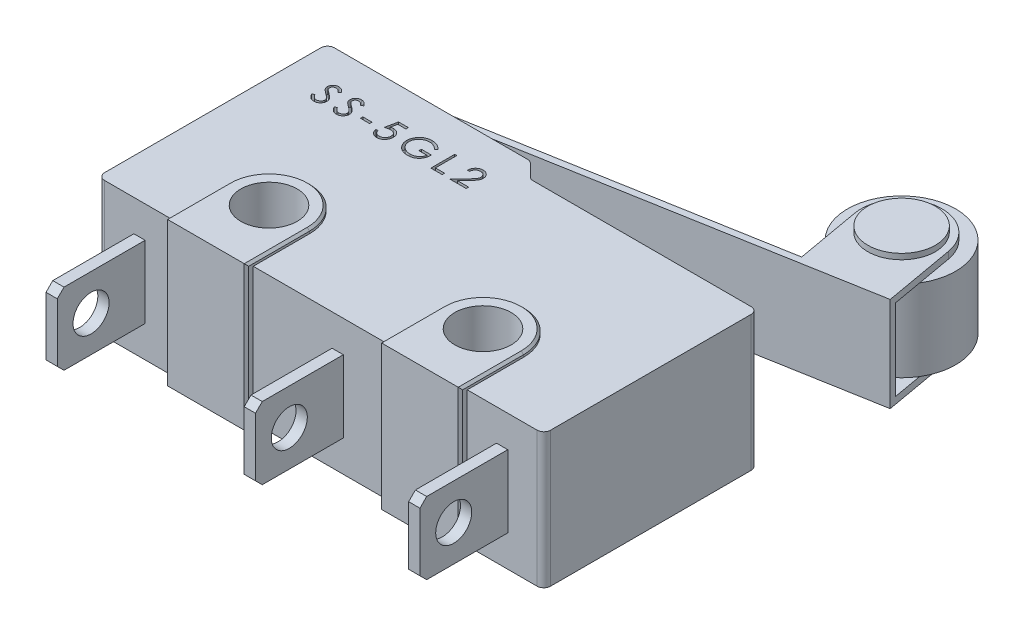
from build123d import *

# Parameters (mm, degrees)
BASE_EXTRUDE_DEPTH       = 6
SKETCH2_R                = 1.25
CUT_EXTRUDE1_DEPTH       = 24.066859344
SKETCH3_R                = 1.25
BOSS_EXTRUDE1_DEPTH      = 0.2
SKETCH4_R                = 1.25
BOSS_EXTRUDE2_DEPTH      = 0.2
CHAMFER1_SIZE            = 0.1
SKETCH5_W                = 2
SKETCH5_H                = 3.2
BOSS_EXTRUDE3_DEPTH      = 1.2
FILLET1_R                = 0.7
SKETCH6_W                = 0.5
SKETCH6_H                = 3.2
BOSS_EXTRUDE4_DEPTH      = 3.9
CHAMFER2_SIZE            = 0.3
SKETCH7_R                = 0.8
CUT_EXTRUDE2_DEPTH       = 23.352628481
BOSS_EXTRUDE5_DEPTH      = 0.3
CHAMFER3_SIZE            = 0.1
BOSS_EXTRUDE6_DEPTH      = 2.1
BOSS_EXTRUDE6_DEPTH_BACK = 2.1
SKETCH12_W               = 0.407051282
SKETCH12_H               = 0.108547009
CUT_EXTRUDE3_DEPTH       = 0.3
SKETCH13_R               = 1.5
EXTRUDE1_DEPTH           = 0.25
SKETCH14_R               = 0.9
EXTRUDE2_DEPTH           = 0.25
SKETCH15_W               = 3.6
SKETCH15_H               = 3.6
CUT_EXTRUDE4_DEPTH       = 28.708764663
SKETCH16_R               = 2.4
EXTRUDE3_DEPTH           = 3.6


with BuildPart() as part:
    # Sketch1 → Base-Extrude (new body)
    with BuildSketch(Plane(origin=(0, 0, 0), x_dir=(1, 0, 0), z_dir=(0, 1, 0))):
        with BuildLine():
            Line((19.5, 9.5), (9.824264069, 9.5))
            ThreePointArc((9.824264069, 9.5), (9.709459039, 9.52283614), (9.612132034, 9.587867966))
            Line((9.612132034, 9.587867966), (9.087867966, 10.112132034))
            ThreePointArc((9.087867966, 10.112132034), (8.990540961, 10.17716386), (8.875735931, 10.2))
            Line((8.875735931, 10.2), (0.3, 10.2))
            ThreePointArc((0.3, 10.2), (0.087867966, 10.112132034), (0, 9.9))
            Line((0, 9.9), (0, 0.3))
            ThreePointArc((0, 0.3), (0.087867966, 0.087867966), (0.3, 0))
            Line((0.3, 0), (19.5, 0))
            ThreePointArc((19.5, 0), (19.712132034, 0.087867966), (19.8, 0.3))
            Line((19.8, 0.3), (19.8, 9.2))
            ThreePointArc((19.8, 9.2), (19.712132034, 9.412132034), (19.5, 9.5))
        make_face()
    extrude(amount=BASE_EXTRUDE_DEPTH)

    # Sketch2 → Cut-Extrude1 (cut, through all)
    with BuildSketch(Plane(origin=(0, 6, 0), x_dir=(-1, 0, 0), z_dir=(0, 1, 0))):
        with Locations(Location((-5.1, -2.5, 0), (0, 0, 90))):
            Circle(SKETCH2_R)
        with Locations(Location((-14.6, -2.5, 0), (0, 0, 90))):
            Circle(SKETCH2_R)
    extrude(amount=-CUT_EXTRUDE1_DEPTH, mode=Mode.SUBTRACT)

    # Sketch3 → Boss-Extrude1 (add)
    with BuildSketch(Plane(origin=(0, 6, 0), x_dir=(-1, 0, 0), z_dir=(0, 1, 0))):
        with BuildLine():
            Line((-3.3, 0), (-6.9, 0))
            Line((-6.9, 0), (-6.9, -2.5))
            ThreePointArc((-6.9, -2.5), (-5.1, -4.3), (-3.3, -2.5))
            Line((-3.3, -2.5), (-3.3, 0))
        make_face()
        with Locations(Location((-5.1, -2.5, 0), (0, 0, 90))):
            Circle(SKETCH3_R, mode=Mode.SUBTRACT)
        with BuildLine():
            Line((-12.8, -2.5), (-12.8, 0))
            Line((-12.8, 0), (-16.4, 0))
            Line((-16.4, 0), (-16.4, -2.5))
            ThreePointArc((-16.4, -2.5), (-14.6, -4.3), (-12.8, -2.5))
        make_face()
        with Locations(Location((-14.6, -2.5, 0), (0, 0, 90))):
            Circle(SKETCH3_R, mode=Mode.SUBTRACT)
    extrude(amount=BOSS_EXTRUDE1_DEPTH)

    # Sketch4 → Boss-Extrude2 (add)
    with BuildSketch(Plane.XZ):
        with BuildLine():
            Line((16.4, 0), (12.8, 0))
            Line((12.8, 0), (12.8, -2.5))
            ThreePointArc((12.8, -2.5), (14.6, -4.3), (16.4, -2.5))
            Line((16.4, -2.5), (16.4, 0))
        make_face()
        with Locations(Location((14.6, -2.5, 0), (0, 0, 90))):
            Circle(SKETCH4_R, mode=Mode.SUBTRACT)
        with BuildLine():
            Line((3.3, 0), (3.3, -2.5))
            ThreePointArc((3.3, -2.5), (5.1, -4.3), (6.9, -2.5))
            Line((6.9, -2.5), (6.9, 0))
            Line((6.9, 0), (3.3, 0))
        make_face()
        with Locations(Location((5.1, -2.5, 0), (0, 0, 90))):
            Circle(SKETCH4_R, mode=Mode.SUBTRACT)
    extrude(amount=BOSS_EXTRUDE2_DEPTH)

    # Chamfer1
    chamfer1_edges = [part.edges().sort_by_distance(p)[0] for p in [
        (3.3, 6.2, -1.25),
        (6.9, 6.2, -1.25),
        (5.1, 6.2, -4.3),
        (16.4, 6.2, -1.25),
        (14.6, 6.2, -4.3),
        (12.8, 6.2, -1.25),
        (12.8, -0.2, -1.25),
        (14.6, -0.2, -4.3),
        (16.4, -0.2, -1.25),
        (5.1, -0.2, -4.3),
        (6.9, -0.2, -1.25),
        (3.3, -0.2, -1.25),
    ]]
    chamfer(chamfer1_edges, length=CHAMFER1_SIZE)

    # Sketch5 → Boss-Extrude3 (add)
    with BuildSketch(Plane(origin=(0, 0, -10.2), x_dir=(-1, 0, 0), z_dir=(0, 0, -1))):
        with Locations((-7.1, 3)):
            Rectangle(SKETCH5_W, SKETCH5_H)
    extrude(amount=BOSS_EXTRUDE3_DEPTH)

    # Fillet1
    fillet1_edges = [part.edges().sort_by_distance(p)[0] for p in [
        (8.1, 3, -11.4),
        (6.1, 3, -11.4),
    ]]
    fillet(fillet1_edges, radius=FILLET1_R)

    # Sketch6 → Boss-Extrude4 (add)
    with BuildSketch(Plane.XY):
        with Locations((1.85, 3)):
            Rectangle(SKETCH6_W, SKETCH6_H)
        with Locations((10.65, 3)):
            Rectangle(SKETCH6_W, SKETCH6_H)
        with Locations((17.95, 3)):
            Rectangle(SKETCH6_W, SKETCH6_H)
    extrude(amount=BOSS_EXTRUDE4_DEPTH)

    # Chamfer2
    chamfer2_edges = [part.edges().sort_by_distance(p)[0] for p in [
        (1.85, 1.4, 3.9),
        (1.85, 4.6, 3.9),
        (10.65, 1.4, 3.9),
        (10.65, 4.6, 3.9),
        (17.95, 1.4, 3.9),
        (17.95, 4.6, 3.9),
    ]]
    chamfer(chamfer2_edges, length=CHAMFER2_SIZE)

    # Sketch7 → Cut-Extrude2 (cut, through all)
    with BuildSketch(Plane.ZY.offset(-1.6)):
        with Locations((2.4, 3)):
            Circle(SKETCH7_R)
    extrude(amount=-CUT_EXTRUDE2_DEPTH, mode=Mode.SUBTRACT)

    # Sketch8 → Boss-Extrude5 (add)
    with BuildSketch(Plane.XY):
        Polygon((16.4, -0.1), (16.4, 6.1), (16.3, 6.2), (12.9, 6.2), (12.8, 6.1), (12.8, -0.1), (12.9, -0.2), (16.3, -0.2), align=None)
        Polygon((6.9, -0.1), (6.9, 6.1), (6.8, 6.2), (3.4, 6.2), (3.3, 6.1), (3.3, -0.1), (3.4, -0.2), (6.8, -0.2), align=None)
    extrude(amount=BOSS_EXTRUDE5_DEPTH)

    # Chamfer3
    chamfer3_edges = [part.edges().sort_by_distance(p)[0] for p in [
        (12.8, 3, 0.3),
        (16.4, 3, 0.3),
        (3.3, 3, 0.3),
        (6.9, 3, 0.3),
    ]]
    chamfer(chamfer3_edges, length=CHAMFER3_SIZE)

    # Sketch11 → Boss-Extrude6 (add, two sides)
    with BuildSketch(Plane(origin=(0, 3, 0), x_dir=(-1, 0, 0), z_dir=(0, 1, 0))) as boss_extrude6_sk:
        with BuildLine():
            Line((-17.815964753, -13.430390492), (-2.947649136, -10.795396999))
            ThreePointArc((-2.947649136, -10.795396999), (-2.770103002, -10.692736531), (-2.7, -10.5))
            Line((-2.7, -10.5), (-2.7, -10.2))
            Line((-2.7, -10.2), (-3, -10.2))
            Line((-3, -10.2), (-3, -10.5))
            Line((-3, -10.5), (-21.413079605, -13.763203862))
            Line((-21.413079605, -13.763203862), (-20.854670388, -16.914105185))
            ThreePointArc((-20.854670388, -16.914105185), (-18.76818321, -18.372381994), (-17.3099064, -16.285894815))
            Line((-17.3099064, -16.285894815), (-17.815964753, -13.430390492))
        make_face()
    extrude(amount=BOSS_EXTRUDE6_DEPTH)
    extrude(boss_extrude6_sk.sketch, amount=-BOSS_EXTRUDE6_DEPTH_BACK)

    # Sketch12 → Cut-Extrude3 (cut)
    with BuildSketch(Plane(origin=(-12.497117176, 6, -3.291404599), x_dir=(1, 0, 0), z_dir=(0, 1, 0))):
        with BuildLine():
            Line((14.069489931, 4.629493769), (14.158956411, 4.683131256))
            add(Edge.make_bspline(
                [(14.158956411, 4.683131256), (14.167277401, 4.669202263), (14.183220099, 4.642514851), (14.209814914, 4.606453491), (14.237371771, 4.575803506), (14.266094736, 4.550743198), (14.295808487, 4.531013178), (14.326706999, 4.517042503), (14.358686146, 4.508329101), (14.380449659, 4.507270741), (14.391314851, 4.506742367)],
                knots=[0, 0, 0, 0, 1.272034388, 2.437168799, 3.508375237, 4.49857839, 5.41946034, 6.295179144, 7.148887113, 8, 8, 8, 8], degree=3))
            add(Edge.make_bspline(
                [(14.391314851, 4.506742367), (14.400593973, 4.507000804), (14.418989854, 4.507513155), (14.446071771, 4.512436159), (14.472373411, 4.519999351), (14.497352689, 4.530830918), (14.520664935, 4.543935651), (14.541107912, 4.559764138), (14.558780903, 4.577485538), (14.573237469, 4.597256007), (14.584328813, 4.618518574), (14.592853557, 4.640343207), (14.597584329, 4.66307275), (14.598296967, 4.67837639), (14.598656598, 4.686099338)],
                knots=[0, 0, 0, 0, 1.095163259, 2.171163733, 3.241058638, 4.321873601, 5.38011039, 6.391990106, 7.366004449, 8.327778327, 9.272591725, 10.192022065, 11.087607919, 12, 12, 12, 12], degree=3))
            add(Edge.make_bspline(
                [(14.598656598, 4.686099338), (14.598210794, 4.694910976), (14.597304541, 4.712823748), (14.589644784, 4.739251738), (14.577595131, 4.765405444), (14.566478807, 4.781583208), (14.560707546, 4.789982217)],
                knots=[0, 0, 0, 0, 0.938893495, 1.908633276, 2.914225137, 4, 4, 4, 4], degree=3))
            add(Edge.make_bspline(
                [(14.560707546, 4.789982217), (14.555969051, 4.796043995), (14.546021173, 4.808769939), (14.528919258, 4.827712665), (14.508851409, 4.847252044), (14.486504382, 4.868134187), (14.461064138, 4.889387878), (14.433327485, 4.912026619), (14.402586271, 4.935189477), (14.381026661, 4.950723562), (14.369902257, 4.958738895)],
                knots=[0, 0, 0, 0, 0.722233717, 1.516239348, 2.393582979, 3.351407094, 4.387010283, 5.505090956, 6.712668013, 8, 8, 8, 8], degree=3))
            add(Edge.make_bspline(
                [(14.369902257, 4.958738895), (14.358767382, 4.96666992), (14.337478349, 4.981833436), (14.307706349, 5.004337922), (14.281083381, 5.024913092), (14.257727773, 5.043752639), (14.2376498, 5.060859117), (14.220691245, 5.076068256), (14.20728411, 5.08979138), (14.199828732, 5.098693881), (14.196481451, 5.102690885)],
                knots=[0, 0, 0, 0, 1.452282411, 2.77665338, 3.964542531, 5.026858415, 5.96415736, 6.766646006, 7.446254459, 8, 8, 8, 8], degree=3))
            add(Edge.make_bspline(
                [(14.196481451, 5.102690885), (14.191802848, 5.108920246), (14.182601747, 5.12117112), (14.170456312, 5.140319351), (14.16013328, 5.159920672), (14.15204086, 5.180027755), (14.145226337, 5.200358317), (14.140642867, 5.221177622), (14.13777285, 5.242392252), (14.137478939, 5.256668715), (14.137331811, 5.26381535)],
                knots=[0, 0, 0, 0, 1.068054152, 2.10047183, 3.106115577, 4.101338837, 5.06977816, 6.043150881, 7.020423561, 8, 8, 8, 8], degree=3))
            add(Edge.make_bspline(
                [(14.137331811, 5.26381535), (14.137726482, 5.275012449), (14.138507387, 5.297167316), (14.145111543, 5.3295314), (14.155535489, 5.360430626), (14.170138944, 5.389559084), (14.188964381, 5.416158321), (14.210749712, 5.440534304), (14.236697471, 5.461026233), (14.26516743, 5.478930831), (14.296329714, 5.492944956), (14.328984107, 5.503516491), (14.363182507, 5.509506433), (14.386345836, 5.510366031), (14.398099039, 5.510802196)],
                knots=[0, 0, 0, 0, 1.005424448, 1.989358655, 2.955360095, 3.929531133, 4.905563448, 5.876582895, 6.856512386, 7.866279853, 8.892233794, 9.918561126, 10.94386622, 12, 12, 12, 12], degree=3))
            add(Edge.make_bspline(
                [(14.398099039, 5.510802196), (14.410570469, 5.510372043), (14.435372164, 5.509516607), (14.471854188, 5.502078782), (14.506978976, 5.489771675), (14.53523444, 5.475805104), (14.557348394, 5.461855843), (14.574213006, 5.449149848), (14.591302807, 5.434522137), (14.608755647, 5.417933746), (14.626275799, 5.399232466), (14.644123366, 5.378546377), (14.662340086, 5.356001895), (14.67405912, 5.339907819), (14.680066854, 5.331657231)],
                knots=[0, 0, 0, 0, 1.286793592, 2.559021753, 3.825965368, 5.121522368, 5.803751409, 6.523245864, 7.299691795, 8.125521123, 9.008227632, 9.944561021, 10.946284179, 12, 12, 12, 12], degree=3))
            Line((14.680066854, 5.331657231), (14.594204474, 5.266571427))
            add(Edge.make_bspline(
                [(14.594204474, 5.266571427), (14.589019871, 5.273250626), (14.579035537, 5.286113202), (14.563877335, 5.304126433), (14.549590244, 5.32058094), (14.53551429, 5.334873015), (14.522392882, 5.347785326), (14.509657491, 5.3588403), (14.497491389, 5.368146254), (14.482155561, 5.378077521), (14.462888537, 5.387921988), (14.438702737, 5.396252304), (14.413427839, 5.40125824), (14.396213403, 5.401920117), (14.387498745, 5.402255187)],
                knots=[0, 0, 0, 0, 1.181633172, 2.275549214, 3.290209073, 4.226197932, 5.078386478, 5.862611352, 6.581680152, 7.217281963, 8.414376989, 9.595101626, 10.782541182, 12, 12, 12, 12], degree=3))
            add(Edge.make_bspline(
                [(14.387498745, 5.402255187), (14.376565701, 5.401888792), (14.355482357, 5.401182234), (14.325549595, 5.393465477), (14.298609289, 5.381315248), (14.275461251, 5.364286671), (14.256188403, 5.344111514), (14.242246991, 5.32089505), (14.23385587, 5.295258467), (14.232831923, 5.277375156), (14.232310444, 5.268267474)],
                knots=[0, 0, 0, 0, 1.14458467, 2.207223713, 3.21896685, 4.227309161, 5.202851033, 6.127160689, 7.046193047, 8, 8, 8, 8], degree=3))
            add(Edge.make_bspline(
                [(14.232310444, 5.268267474), (14.232429318, 5.262597384), (14.23266726, 5.251247932), (14.23598583, 5.234480478), (14.240249199, 5.217755383), (14.247005185, 5.20114784), (14.256332217, 5.184367403), (14.268580211, 5.167125116), (14.284005665, 5.149269004), (14.295821809, 5.137655345), (14.302060377, 5.131523684)],
                knots=[0, 0, 0, 0, 0.858281714, 1.717966888, 2.583508476, 3.4729293, 4.427298488, 5.488583878, 6.674047936, 8, 8, 8, 8], degree=3))
            add(Edge.make_bspline(
                [(14.302060377, 5.131523684), (14.30437703, 5.129456297), (14.309880868, 5.12454466), (14.319942874, 5.116503661), (14.333230339, 5.106584728), (14.34939629, 5.094311896), (14.368738802, 5.080075359), (14.391260001, 5.064057148), (14.416708846, 5.045737259), (14.434767615, 5.032929145), (14.44431632, 5.026156763)],
                knots=[0, 0, 0, 0, 0.420754252, 0.999615792, 1.744751191, 2.668019286, 3.750313428, 4.999500688, 6.413464383, 8, 8, 8, 8], degree=3))
            add(Edge.make_bspline(
                [(14.44431632, 5.026156763), (14.455802537, 5.017798543), (14.478044003, 5.001614007), (14.509690462, 4.977297837), (14.538384542, 4.95351625), (14.564226987, 4.930421116), (14.5874731, 4.908187621), (14.607864982, 4.886548279), (14.625610414, 4.865658117), (14.644714606, 4.838875458), (14.664235661, 4.80598213), (14.681000117, 4.765681329), (14.691570855, 4.72522387), (14.692953194, 4.698031708), (14.69363523, 4.684615297)],
                knots=[0, 0, 0, 0, 1.163667725, 2.253281268, 3.268753668, 4.215851969, 5.092017293, 5.902905408, 6.650798638, 7.335211899, 8.59617414, 9.77448103, 10.901945474, 12, 12, 12, 12], degree=3))
            add(Edge.make_bspline(
                [(14.69363523, 4.684615297), (14.693436524, 4.675127077), (14.693042971, 4.656334892), (14.688519075, 4.628741095), (14.681890986, 4.601940808), (14.671901156, 4.576265305), (14.659708201, 4.551244865), (14.644236502, 4.527535809), (14.626302988, 4.504613398), (14.605730873, 4.483088866), (14.58321985, 4.463329421), (14.5594274, 4.4457523), (14.534314579, 4.431096403), (14.508017622, 4.419136981), (14.480530486, 4.409783275), (14.451862419, 4.40300605), (14.421966162, 4.398846585), (14.401646016, 4.398414857), (14.391314851, 4.398195358)],
                knots=[0, 0, 0, 0, 0.983748083, 1.948392443, 2.894712957, 3.844097841, 4.80183111, 5.778335162, 6.776009319, 7.81870978, 8.863265674, 9.881300176, 10.883814829, 11.87499822, 12.874611388, 13.892143829, 14.928324115, 16, 16, 16, 16], degree=3))
            add(Edge.make_bspline(
                [(14.391314851, 4.398195358), (14.383321307, 4.39834993), (14.367434889, 4.398657126), (14.343937022, 4.401372895), (14.32091386, 4.405215281), (14.298654303, 4.411315535), (14.276871562, 4.418716907), (14.255660375, 4.427830164), (14.235010461, 4.438751318), (14.214806096, 4.451238147), (14.195098667, 4.465769894), (14.176073019, 4.482695213), (14.157104908, 4.501547306), (14.138754195, 4.522838119), (14.120649697, 4.546223682), (14.103148368, 4.571922793), (14.085887944, 4.599795469), (14.075058029, 4.619409435), (14.069489931, 4.629493769)],
                knots=[0, 0, 0, 0, 0.915332311, 1.819136955, 2.706846663, 3.586547465, 4.459518054, 5.340707479, 6.227863349, 7.133153174, 8.059268498, 9.028702269, 10.047606654, 11.120612155, 12.245963614, 13.433783089, 14.680604001, 16, 16, 16, 16], degree=3))
        make_face()
        with BuildLine():
            Line((15.070836085, 4.629493769), (15.160302565, 4.683131256))
            add(Edge.make_bspline(
                [(15.160302565, 4.683131256), (15.168623555, 4.669202263), (15.184566253, 4.642514851), (15.211161068, 4.606453491), (15.238717925, 4.575803506), (15.26744089, 4.550743198), (15.297154641, 4.531013178), (15.328053152, 4.517042503), (15.3600323, 4.508329101), (15.381795813, 4.507270741), (15.392661005, 4.506742367)],
                knots=[0, 0, 0, 0, 1.272034388, 2.437168799, 3.508375237, 4.49857839, 5.41946034, 6.295179144, 7.148887113, 8, 8, 8, 8], degree=3))
            add(Edge.make_bspline(
                [(15.392661005, 4.506742367), (15.401940127, 4.507000804), (15.420336008, 4.507513155), (15.447417925, 4.512436159), (15.473719565, 4.519999351), (15.498698843, 4.530830918), (15.522011089, 4.543935651), (15.542454066, 4.559764138), (15.560127057, 4.577485538), (15.574583623, 4.597256007), (15.585674967, 4.618518574), (15.594199711, 4.640343207), (15.598930483, 4.66307275), (15.599643121, 4.67837639), (15.600002752, 4.686099338)],
                knots=[0, 0, 0, 0, 1.095163259, 2.171163733, 3.241058638, 4.321873601, 5.38011039, 6.391990106, 7.366004449, 8.327778327, 9.272591725, 10.192022065, 11.087607919, 12, 12, 12, 12], degree=3))
            add(Edge.make_bspline(
                [(15.600002752, 4.686099338), (15.599556948, 4.694910976), (15.598650695, 4.712823748), (15.590990938, 4.739251738), (15.578941284, 4.765405444), (15.567824961, 4.781583208), (15.5620537, 4.789982217)],
                knots=[0, 0, 0, 0, 0.938893495, 1.908633276, 2.914225137, 4, 4, 4, 4], degree=3))
            add(Edge.make_bspline(
                [(15.5620537, 4.789982217), (15.557315204, 4.796043995), (15.547367326, 4.808769939), (15.530265412, 4.827712665), (15.510197563, 4.847252044), (15.487850536, 4.868134187), (15.462410292, 4.889387878), (15.434673639, 4.912026619), (15.403932425, 4.935189477), (15.382372815, 4.950723562), (15.371248411, 4.958738895)],
                knots=[0, 0, 0, 0, 0.722233717, 1.516239348, 2.393582979, 3.351407094, 4.387010283, 5.505090956, 6.712668013, 8, 8, 8, 8], degree=3))
            add(Edge.make_bspline(
                [(15.371248411, 4.958738895), (15.360113536, 4.96666992), (15.338824503, 4.981833436), (15.309052503, 5.004337922), (15.282429535, 5.024913092), (15.259073927, 5.043752639), (15.238995954, 5.060859117), (15.222037399, 5.076068256), (15.208630263, 5.08979138), (15.201174886, 5.098693881), (15.197827605, 5.102690885)],
                knots=[0, 0, 0, 0, 1.452282411, 2.77665338, 3.964542531, 5.026858415, 5.96415736, 6.766646006, 7.446254459, 8, 8, 8, 8], degree=3))
            add(Edge.make_bspline(
                [(15.197827605, 5.102690885), (15.193149002, 5.108920246), (15.183947901, 5.12117112), (15.171802466, 5.140319351), (15.161479433, 5.159920672), (15.153387014, 5.180027755), (15.146572491, 5.200358317), (15.141989021, 5.221177622), (15.139119004, 5.242392252), (15.138825093, 5.256668715), (15.138677965, 5.26381535)],
                knots=[0, 0, 0, 0, 1.068054152, 2.10047183, 3.106115577, 4.101338837, 5.06977816, 6.043150881, 7.020423561, 8, 8, 8, 8], degree=3))
            add(Edge.make_bspline(
                [(15.138677965, 5.26381535), (15.139072636, 5.275012449), (15.13985354, 5.297167316), (15.146457697, 5.3295314), (15.156881643, 5.360430626), (15.171485097, 5.389559084), (15.190310535, 5.416158321), (15.212095865, 5.440534304), (15.238043624, 5.461026233), (15.266513584, 5.478930831), (15.297675868, 5.492944956), (15.33033026, 5.503516491), (15.364528661, 5.509506433), (15.38769199, 5.510366031), (15.399445193, 5.510802196)],
                knots=[0, 0, 0, 0, 1.005424448, 1.989358655, 2.955360095, 3.929531133, 4.905563448, 5.876582895, 6.856512386, 7.866279853, 8.892233794, 9.918561126, 10.94386622, 12, 12, 12, 12], degree=3))
            add(Edge.make_bspline(
                [(15.399445193, 5.510802196), (15.411916623, 5.510372043), (15.436718318, 5.509516607), (15.473200342, 5.502078782), (15.50832513, 5.489771675), (15.536580594, 5.475805104), (15.558694548, 5.461855843), (15.57555916, 5.449149848), (15.59264896, 5.434522137), (15.610101801, 5.417933746), (15.627621953, 5.399232466), (15.64546952, 5.378546377), (15.66368624, 5.356001895), (15.675405274, 5.339907819), (15.681413008, 5.331657231)],
                knots=[0, 0, 0, 0, 1.286793592, 2.559021753, 3.825965368, 5.121522368, 5.803751409, 6.523245864, 7.299691795, 8.125521123, 9.008227632, 9.944561021, 10.946284179, 12, 12, 12, 12], degree=3))
            Line((15.681413008, 5.331657231), (15.595550628, 5.266571427))
            add(Edge.make_bspline(
                [(15.595550628, 5.266571427), (15.590366025, 5.273250626), (15.580381691, 5.286113202), (15.565223489, 5.304126433), (15.550936398, 5.32058094), (15.536860443, 5.334873015), (15.523739036, 5.347785326), (15.511003644, 5.3588403), (15.498837543, 5.368146254), (15.483501715, 5.378077521), (15.464234691, 5.387921988), (15.440048891, 5.396252304), (15.414773993, 5.40125824), (15.397559557, 5.401920117), (15.388844899, 5.402255187)],
                knots=[0, 0, 0, 0, 1.181633172, 2.275549214, 3.290209073, 4.226197932, 5.078386478, 5.862611352, 6.581680152, 7.217281963, 8.414376989, 9.595101626, 10.782541182, 12, 12, 12, 12], degree=3))
            add(Edge.make_bspline(
                [(15.388844899, 5.402255187), (15.377911855, 5.401888792), (15.35682851, 5.401182234), (15.326895749, 5.393465477), (15.299955443, 5.381315248), (15.276807405, 5.364286671), (15.257534557, 5.344111514), (15.243593145, 5.32089505), (15.235202024, 5.295258467), (15.234178077, 5.277375156), (15.233656598, 5.268267474)],
                knots=[0, 0, 0, 0, 1.14458467, 2.207223713, 3.21896685, 4.227309161, 5.202851033, 6.127160689, 7.046193047, 8, 8, 8, 8], degree=3))
            add(Edge.make_bspline(
                [(15.233656598, 5.268267474), (15.233775472, 5.262597384), (15.234013414, 5.251247932), (15.237331984, 5.234480478), (15.241595352, 5.217755383), (15.248351339, 5.20114784), (15.257678371, 5.184367403), (15.269926365, 5.167125116), (15.285351818, 5.149269004), (15.297167963, 5.137655345), (15.303406531, 5.131523684)],
                knots=[0, 0, 0, 0, 0.858281714, 1.717966888, 2.583508476, 3.4729293, 4.427298488, 5.488583878, 6.674047936, 8, 8, 8, 8], degree=3))
            add(Edge.make_bspline(
                [(15.303406531, 5.131523684), (15.305723184, 5.129456297), (15.311227021, 5.12454466), (15.321289028, 5.116503661), (15.334576493, 5.106584728), (15.350742444, 5.094311896), (15.370084956, 5.080075359), (15.392606155, 5.064057148), (15.418054999, 5.045737259), (15.436113769, 5.032929145), (15.445662474, 5.026156763)],
                knots=[0, 0, 0, 0, 0.420754252, 0.999615792, 1.744751191, 2.668019286, 3.750313428, 4.999500688, 6.413464383, 8, 8, 8, 8], degree=3))
            add(Edge.make_bspline(
                [(15.445662474, 5.026156763), (15.45714869, 5.017798543), (15.479390157, 5.001614007), (15.511036616, 4.977297837), (15.539730696, 4.95351625), (15.565573141, 4.930421116), (15.588819253, 4.908187621), (15.609211136, 4.886548279), (15.626956567, 4.865658117), (15.64606076, 4.838875458), (15.665581815, 4.80598213), (15.682346271, 4.765681329), (15.692917009, 4.72522387), (15.694299348, 4.698031708), (15.694981384, 4.684615297)],
                knots=[0, 0, 0, 0, 1.163667725, 2.253281268, 3.268753668, 4.215851969, 5.092017293, 5.902905408, 6.650798638, 7.335211899, 8.59617414, 9.77448103, 10.901945474, 12, 12, 12, 12], degree=3))
            add(Edge.make_bspline(
                [(15.694981384, 4.684615297), (15.694782678, 4.675127077), (15.694389125, 4.656334892), (15.689865229, 4.628741095), (15.68323714, 4.601940808), (15.67324731, 4.576265305), (15.661054355, 4.551244865), (15.645582656, 4.527535809), (15.627649142, 4.504613398), (15.607077027, 4.483088866), (15.584566004, 4.463329421), (15.560773554, 4.4457523), (15.535660733, 4.431096403), (15.509363775, 4.419136981), (15.48187664, 4.409783275), (15.453208572, 4.40300605), (15.423312315, 4.398846585), (15.40299217, 4.398414857), (15.392661005, 4.398195358)],
                knots=[0, 0, 0, 0, 0.983748083, 1.948392443, 2.894712957, 3.844097841, 4.80183111, 5.778335162, 6.776009319, 7.81870978, 8.863265674, 9.881300176, 10.883814829, 11.87499822, 12.874611388, 13.892143829, 14.928324115, 16, 16, 16, 16], degree=3))
            add(Edge.make_bspline(
                [(15.392661005, 4.398195358), (15.384667461, 4.39834993), (15.368781043, 4.398657126), (15.345283175, 4.401372895), (15.322260014, 4.405215281), (15.300000457, 4.411315535), (15.278217716, 4.418716907), (15.257006529, 4.427830164), (15.236356615, 4.438751318), (15.21615225, 4.451238147), (15.196444821, 4.465769894), (15.177419173, 4.482695213), (15.158451062, 4.501547306), (15.140100349, 4.522838119), (15.121995851, 4.546223682), (15.104494522, 4.571922793), (15.087234098, 4.599795469), (15.076404183, 4.619409435), (15.070836085, 4.629493769)],
                knots=[0, 0, 0, 0, 0.915332311, 1.819136955, 2.706846663, 3.586547465, 4.459518054, 5.340707479, 6.227863349, 7.133153174, 8.059268498, 9.028702269, 10.047606654, 11.120612155, 12.245963614, 13.433783089, 14.680604001, 16, 16, 16, 16], degree=3))
        make_face()
        with Locations((16.289276256, 4.832383393)):
            Rectangle(SKETCH12_W, SKETCH12_H)
        with BuildLine():
            Line((17.507716427, 5.483665444), (17.507716427, 5.375118435))
            Line((17.507716427, 5.375118435), (17.147730449, 5.375118435))
            Line((17.147730449, 5.375118435), (17.090700868, 5.09675472))
            add(Edge.make_bspline(
                [(17.090700868, 5.09675472), (17.101905859, 5.099848159), (17.123613756, 5.105841209), (17.155654, 5.112495335), (17.186071166, 5.116506552), (17.205809195, 5.117054258), (17.215360324, 5.11731929)],
                knots=[0, 0, 0, 0, 1.100273476, 2.13160584, 3.095893838, 4, 4, 4, 4], degree=3))
            add(Edge.make_bspline(
                [(17.215360324, 5.11731929), (17.227178502, 5.117063495), (17.250415994, 5.116560539), (17.28441539, 5.111730956), (17.316870812, 5.104129124), (17.347714386, 5.093509347), (17.377003171, 5.079929499), (17.404467696, 5.062965946), (17.430520208, 5.043149915), (17.454693325, 5.020367019), (17.476623295, 4.995293101), (17.495904915, 4.968333459), (17.512282651, 4.939750095), (17.525454594, 4.909269911), (17.535972714, 4.877229881), (17.542973436, 4.843292886), (17.547635155, 4.807778811), (17.548155972, 4.783496239), (17.548421555, 4.771113694)],
                knots=[0, 0, 0, 0, 1.052922333, 2.070308379, 3.05430497, 4.020497103, 4.973039431, 5.925935799, 6.892292201, 7.88610001, 8.88166317, 9.857072816, 10.836096531, 11.812156883, 12.81219415, 13.836441305, 14.89672472, 16, 16, 16, 16], degree=3))
            add(Edge.make_bspline(
                [(17.548421555, 4.771113694), (17.548220449, 4.762489118), (17.547820954, 4.74535652), (17.545789381, 4.719912916), (17.541877867, 4.695007964), (17.536626198, 4.67063836), (17.529809801, 4.64685024), (17.52155811, 4.623575516), (17.511459788, 4.600959052), (17.500383158, 4.578786849), (17.487911008, 4.557560158), (17.47406846, 4.537709155), (17.459443656, 4.51893605), (17.443707333, 4.501442184), (17.426713222, 4.485342509), (17.408667137, 4.470541481), (17.389713077, 4.456788793), (17.369557801, 4.444642696), (17.348650431, 4.433465802), (17.326689042, 4.424296542), (17.304173544, 4.416098835), (17.28077988, 4.409564525), (17.256561036, 4.404444443), (17.231477092, 4.400966881), (17.205659604, 4.398434006), (17.188159302, 4.39827545), (17.179319325, 4.398195358)],
                knots=[0, 0, 0, 0, 1.056347294, 2.098418968, 3.122841568, 4.141288669, 5.149314143, 6.15115421, 7.162517403, 8.180376062, 9.185164535, 10.17417709, 11.141909838, 12.097768115, 13.052685741, 14.0056014, 14.954263652, 15.917497458, 16.885230207, 17.854509472, 18.828990115, 19.81800267, 20.826176721, 21.857883937, 22.917946725, 24, 24, 24, 24], degree=3))
            add(Edge.make_bspline(
                [(17.179319325, 4.398195358), (17.168774037, 4.398404255), (17.148027428, 4.398815233), (17.117631924, 4.403114632), (17.088387269, 4.409272293), (17.060528881, 4.418536117), (17.033807094, 4.430143704), (17.008581654, 4.44481407), (16.984208002, 4.461438704), (16.961676982, 4.481057287), (16.94076549, 4.502500838), (16.922046141, 4.525771363), (16.905374798, 4.55048479), (16.891018431, 4.576761136), (16.878772601, 4.604531359), (16.869152354, 4.633899504), (16.861387709, 4.664712124), (16.858102818, 4.68592521), (16.856434375, 4.696699632)],
                knots=[0, 0, 0, 0, 1.0467383, 2.05933395, 3.04377827, 4.011590433, 4.970194871, 5.932262533, 6.905835911, 7.896367577, 8.894135286, 9.877477877, 10.858688626, 11.851381753, 12.8477658, 13.868841284, 14.917554742, 16, 16, 16, 16], degree=3))
            Line((16.856434375, 4.696699632), (16.951413008, 4.696699632))
            add(Edge.make_bspline(
                [(16.951413008, 4.696699632), (16.953749976, 4.686607228), (16.95824176, 4.667209068), (16.968101117, 4.639955068), (16.980155799, 4.615668064), (16.994489971, 4.594026786), (17.011589623, 4.575155494), (17.031102093, 4.558337953), (17.052978666, 4.54316595), (17.077288048, 4.530519542), (17.102933907, 4.51973399), (17.129775421, 4.51255193), (17.157081735, 4.507501898), (17.175550671, 4.50699639), (17.184831477, 4.506742367)],
                knots=[0, 0, 0, 0, 1.136247022, 2.183929868, 3.172523383, 4.106158343, 5.02341133, 5.958108904, 6.928429099, 7.938127109, 8.96079061, 9.975095812, 10.982467395, 12, 12, 12, 12], degree=3))
            add(Edge.make_bspline(
                [(17.184831477, 4.506742367), (17.19389034, 4.506990555), (17.211727316, 4.507479238), (17.237977425, 4.511240558), (17.263320842, 4.517033443), (17.287507495, 4.525702661), (17.310960628, 4.53623904), (17.333086982, 4.549760027), (17.354526661, 4.565320557), (17.374613264, 4.583147919), (17.393009954, 4.602793517), (17.409264781, 4.623802157), (17.422804467, 4.64621368), (17.434214543, 4.669640086), (17.442878755, 4.694338125), (17.449059718, 4.720192052), (17.452689214, 4.747265725), (17.4531885, 4.765731921), (17.453442922, 4.775141806)],
                knots=[0, 0, 0, 0, 1.027316725, 2.022795036, 3.002884548, 3.971462791, 4.93288096, 5.914575861, 6.907176829, 7.935150275, 8.956128384, 9.956726525, 10.942570165, 11.921478529, 12.907843606, 13.90538589, 14.932640048, 16, 16, 16, 16], degree=3))
            add(Edge.make_bspline(
                [(17.453442922, 4.775141806), (17.453243811, 4.783631379), (17.452854078, 4.800248509), (17.449669834, 4.824559697), (17.444131131, 4.847562736), (17.436443434, 4.869368707), (17.426682725, 4.889998177), (17.414754912, 4.909472435), (17.400436146, 4.927534809), (17.384079789, 4.944193747), (17.366161287, 4.959568269), (17.346372345, 4.972674695), (17.325127082, 4.983700689), (17.302681465, 4.993216013), (17.278501603, 5.000050048), (17.253066335, 5.005180813), (17.226100997, 5.008148792), (17.207664623, 5.008560601), (17.198187848, 5.008772281)],
                knots=[0, 0, 0, 0, 1.045622112, 2.046656509, 3.013763289, 3.955457236, 4.890082067, 5.820317437, 6.762574623, 7.722996705, 8.69280354, 9.665887285, 10.63943826, 11.638615906, 12.663482002, 13.728887084, 14.832589034, 16, 16, 16, 16], degree=3))
            add(Edge.make_bspline(
                [(17.198187848, 5.008772281), (17.189984576, 5.008596722), (17.173046902, 5.008234235), (17.147065476, 5.005565271), (17.119762979, 5.00125958), (17.091244072, 4.995337071), (17.061423109, 4.987586722), (17.030363021, 4.978299242), (16.997998502, 4.967195209), (16.976191476, 4.958809516), (16.964981384, 4.954498777)],
                knots=[0, 0, 0, 0, 0.817624296, 1.688186739, 2.600797293, 3.572016777, 4.590301741, 5.671205678, 6.80286297, 8, 8, 8, 8], degree=3))
            Line((16.964981384, 4.954498777), (17.073528393, 5.483665444))
            Line((17.073528393, 5.483665444), (17.507716427, 5.483665444))
        make_face()
        with BuildLine():
            Line((19.011092495, 5.303036437), (18.929682239, 5.225866299))
            add(Edge.make_bspline(
                [(18.929682239, 5.225866299), (18.914950575, 5.239724679), (18.885838532, 5.267110978), (18.838376745, 5.302644064), (18.788857741, 5.333083575), (18.737539915, 5.357850461), (18.685694114, 5.377611891), (18.634008508, 5.391681115), (18.58301326, 5.400653525), (18.549096029, 5.401726484), (18.532383227, 5.402255187)],
                knots=[0, 0, 0, 0, 1.08915593, 2.152340314, 3.188132944, 4.216796309, 5.218260357, 6.173443236, 7.099959455, 8, 8, 8, 8], degree=3))
            add(Edge.make_bspline(
                [(18.532383227, 5.402255187), (18.522128068, 5.402130121), (18.501644346, 5.401880312), (18.471218187, 5.398691942), (18.441111133, 5.394106376), (18.411380017, 5.38747157), (18.381967033, 5.37906264), (18.352974477, 5.368544179), (18.324348267, 5.356281046), (18.296358048, 5.342110726), (18.269222229, 5.326544201), (18.243593376, 5.309293809), (18.219308134, 5.290912437), (18.196822958, 5.270939879), (18.176008509, 5.249557051), (18.156369358, 5.227161718), (18.138596223, 5.20314202), (18.122542466, 5.177939891), (18.108221215, 5.151997967), (18.095579075, 5.125565944), (18.084966384, 5.098731493), (18.076569429, 5.07146094), (18.069641684, 5.043965262), (18.064768026, 5.016054073), (18.062020375, 4.987697487), (18.061545098, 4.968708792), (18.06130617, 4.959162906)],
                knots=[0, 0, 0, 0, 1.02818874, 2.053710826, 3.065248034, 4.081641283, 5.106893873, 6.131558223, 7.173050175, 8.228653731, 9.27666206, 10.308777013, 11.325269123, 12.329503258, 13.32196095, 14.316845687, 15.314881793, 16.315733098, 17.311955233, 18.285320748, 19.252783886, 20.203351036, 21.145449891, 22.095197417, 23.042428769, 24, 24, 24, 24], degree=3))
            add(Edge.make_bspline(
                [(18.06130617, 4.959162906), (18.061534685, 4.949404826), (18.061991091, 4.929915311), (18.064912187, 4.900828056), (18.070333346, 4.872172803), (18.077580724, 4.843855392), (18.086646352, 4.815827324), (18.097947134, 4.788210112), (18.111332209, 4.76100478), (18.126825166, 4.734456453), (18.143814804, 4.70859592), (18.162847593, 4.684236255), (18.18306496, 4.661053077), (18.205203448, 4.63956112), (18.228553167, 4.619185513), (18.253811736, 4.600487629), (18.28048248, 4.583107309), (18.30860609, 4.5672636), (18.337877407, 4.55310959), (18.367890759, 4.540523317), (18.398742027, 4.530157898), (18.430269078, 4.521709947), (18.462434329, 4.514785334), (18.495401051, 4.510330512), (18.528926846, 4.507097809), (18.551526384, 4.506861447), (18.562912073, 4.506742367)],
                knots=[0, 0, 0, 0, 0.93586088, 1.869166235, 2.799637598, 3.729985548, 4.670839027, 5.622275134, 6.589130586, 7.576015415, 8.568469353, 9.55398029, 10.53834874, 11.515998671, 12.510579167, 13.508179873, 14.527009472, 15.561807829, 16.601455013, 17.643573243, 18.680854198, 19.719860599, 20.772568776, 21.833555941, 22.908541556, 24, 24, 24, 24], degree=3))
            add(Edge.make_bspline(
                [(18.562912073, 4.506742367), (18.576633621, 4.507029198), (18.603578109, 4.507592438), (18.643185915, 4.51197705), (18.681226367, 4.518825009), (18.717592576, 4.528853744), (18.75232678, 4.54164557), (18.785556312, 4.557065603), (18.817019552, 4.57570529), (18.846811083, 4.596743102), (18.874254327, 4.620182111), (18.899005455, 4.645474601), (18.920669686, 4.672497802), (18.939569917, 4.701092552), (18.955205629, 4.731495537), (18.968039522, 4.763557765), (18.97787697, 4.797293655), (18.98191526, 4.820604696), (18.983955743, 4.832383393)],
                knots=[0, 0, 0, 0, 1.13008108, 2.219097802, 3.278683437, 4.311054135, 5.322181354, 6.324827112, 7.324222904, 8.330512327, 9.32562643, 10.293043162, 11.24128371, 12.174520618, 13.111833804, 14.052305215, 15.015860969, 16, 16, 16, 16], degree=3))
            Line((18.983955743, 4.832383393), (18.631177965, 4.832383393))
            Line((18.631177965, 4.832383393), (18.631177965, 4.940930401))
            Line((18.631177965, 4.940930401), (19.078934375, 4.940930401))
            add(Edge.make_bspline(
                [(19.078934375, 4.940930401), (19.078418559, 4.920698851), (19.077409014, 4.881102053), (19.07032758, 4.82335628), (19.058892587, 4.768815316), (19.043271493, 4.71742172), (19.023049682, 4.669248324), (18.998444179, 4.624246217), (18.969061181, 4.582706126), (18.935947309, 4.544288927), (18.898784703, 4.510020332), (18.858577525, 4.479901393), (18.815259346, 4.454530841), (18.768871143, 4.433890117), (18.719564774, 4.417781075), (18.667226144, 4.40635967), (18.611926232, 4.3995168), (18.574026808, 4.398642502), (18.554643844, 4.398195358)],
                knots=[0, 0, 0, 0, 1.140356446, 2.231883559, 3.274166699, 4.278491846, 5.25512956, 6.21435461, 7.1637429, 8.11826594, 9.068280886, 10.0076534, 10.945064095, 11.891975133, 12.864533718, 13.863980011, 14.907571808, 16, 16, 16, 16], degree=3))
            add(Edge.make_bspline(
                [(18.554643844, 4.398195358), (18.542696732, 4.39836745), (18.519133175, 4.39870687), (18.484331871, 4.401119067), (18.450490114, 4.40483248), (18.417612835, 4.410440172), (18.385579099, 4.417308651), (18.354548891, 4.42610392), (18.324404007, 4.436284694), (18.295097854, 4.447864576), (18.266896432, 4.46128172), (18.239674128, 4.476192016), (18.213280466, 4.492518579), (18.187895233, 4.510543764), (18.163386161, 4.530132746), (18.139911287, 4.551324788), (18.11733919, 4.574055103), (18.103199717, 4.590195898), (18.096075134, 4.598328905)],
                knots=[0, 0, 0, 0, 1.107784379, 2.184907829, 3.233506516, 4.263428166, 5.276301166, 6.270063455, 7.25232949, 8.225834625, 9.190232166, 10.146266622, 11.1027726, 12.066435141, 13.031522626, 14.010570082, 14.99756817, 16, 16, 16, 16], degree=3))
            add(Edge.make_bspline(
                [(18.096075134, 4.598328905), (18.085737959, 4.611231698), (18.065235196, 4.63682311), (18.038843944, 4.677825951), (18.016346377, 4.720280799), (17.998092298, 4.764305841), (17.983838638, 4.809859899), (17.973616271, 4.85688476), (17.967626924, 4.905440982), (17.966764069, 4.938299288), (17.966327538, 4.954922789)],
                knots=[0, 0, 0, 0, 1.023165419, 2.029347347, 3.013907458, 3.994755782, 4.975994455, 5.96558838, 6.970761222, 8, 8, 8, 8], degree=3))
            add(Edge.make_bspline(
                [(17.966327538, 4.954922789), (17.966488477, 4.96737068), (17.966808308, 4.992108256), (17.9706865, 5.028834632), (17.976250739, 5.064908889), (17.984429253, 5.100301538), (17.994739314, 5.135036217), (18.007606677, 5.169129054), (18.02258811, 5.202600167), (18.040000867, 5.23521917), (18.059378787, 5.266553219), (18.080409449, 5.296476174), (18.10339149, 5.324443105), (18.127949601, 5.350808199), (18.154376786, 5.375240231), (18.182425469, 5.397965403), (18.212117265, 5.419014197), (18.243545586, 5.438055076), (18.276241339, 5.455158837), (18.310126149, 5.47015367), (18.345189673, 5.482546244), (18.381169219, 5.493061173), (18.41833713, 5.500836942), (18.456423686, 5.506475967), (18.49562741, 5.510334529), (18.522126876, 5.510644849), (18.535563315, 5.510802196)],
                knots=[0, 0, 0, 0, 1.008945113, 2.00506715, 2.99143336, 3.967273523, 4.948097931, 5.927297278, 6.919902385, 7.919676788, 8.923139349, 9.905703106, 10.883022732, 11.856032218, 12.825136022, 13.798837087, 14.781400844, 15.773989409, 16.776158564, 17.77167057, 18.775803737, 19.789618931, 20.80898985, 21.851988756, 22.910860228, 24, 24, 24, 24], degree=3))
            add(Edge.make_bspline(
                [(18.535563315, 5.510802196), (18.54652107, 5.510626969), (18.568249009, 5.510279514), (18.600581314, 5.507871156), (18.632413869, 5.504053935), (18.663793872, 5.498844882), (18.694614464, 5.491749909), (18.724963444, 5.483259571), (18.754884806, 5.473374186), (18.784284777, 5.461584702), (18.813361038, 5.448203249), (18.842275262, 5.433140619), (18.870928653, 5.416139248), (18.899370902, 5.397148655), (18.927781364, 5.376495003), (18.955710672, 5.353587582), (18.983832991, 5.329329749), (19.001915921, 5.311887755), (19.011092495, 5.303036437)],
                knots=[0, 0, 0, 0, 0.985871117, 1.954866573, 2.915460327, 3.869826059, 4.81536089, 5.759505086, 6.70452669, 7.649098992, 8.607881297, 9.583363685, 10.581137262, 11.603961102, 12.659522466, 13.73993555, 14.853081303, 16, 16, 16, 16], degree=3))
        make_face()
        Polygon((19.564682239, 5.483665444), (19.659660871, 5.483665444), (19.659660871, 4.533879119), (20.066712153, 4.533879119), (20.066712153, 4.42533211), (19.564682239, 4.42533211), align=None)
        with BuildLine():
            Line((20.552460016, 5.158024418), (20.457481384, 5.158024418))
            add(Edge.make_bspline(
                [(20.457481384, 5.158024418), (20.458100404, 5.170624901), (20.459316143, 5.195371914), (20.465009459, 5.23145319), (20.473155867, 5.265941189), (20.484673997, 5.298558996), (20.498978515, 5.329595016), (20.516132594, 5.358925973), (20.536450735, 5.386439976), (20.5594942, 5.411881959), (20.58452186, 5.435222011), (20.611526275, 5.455377286), (20.639903223, 5.472406677), (20.669566613, 5.486643148), (20.700851117, 5.497329244), (20.733472838, 5.505258169), (20.767575101, 5.510028635), (20.79081006, 5.510541409), (20.80262695, 5.510802196)],
                knots=[0, 0, 0, 0, 1.10065271, 2.161652631, 3.183658789, 4.190468796, 5.17591951, 6.163126047, 7.15150782, 8.156236427, 9.156009102, 10.134482811, 11.092018607, 12.041330605, 13.001268258, 13.972401359, 14.968799086, 16, 16, 16, 16], degree=3))
            add(Edge.make_bspline(
                [(20.80262695, 5.510802196), (20.814231749, 5.51053052), (20.837034764, 5.509996686), (20.87031542, 5.50541228), (20.901998078, 5.498232065), (20.932020808, 5.488158118), (20.96014407, 5.47461616), (20.986579134, 5.458348809), (21.011640712, 5.439534717), (21.034200382, 5.417384159), (21.054915921, 5.393737248), (21.072787317, 5.368492096), (21.088091773, 5.342418002), (21.100848524, 5.315316141), (21.110239309, 5.28693133), (21.11736891, 5.257676819), (21.121398866, 5.227249793), (21.122017363, 5.206655668), (21.122331811, 5.196185476)],
                knots=[0, 0, 0, 0, 1.111607364, 2.184268762, 3.212621178, 4.221274766, 5.211760367, 6.196651075, 7.1921475, 8.207485113, 9.220403448, 10.201281604, 11.166441695, 12.114753415, 13.065576456, 14.026450734, 14.996634279, 16, 16, 16, 16], degree=3))
            add(Edge.make_bspline(
                [(21.122331811, 5.196185476), (21.121819801, 5.181445059), (21.120804765, 5.152222899), (21.112122085, 5.10928031), (21.098561354, 5.067674681), (21.082233582, 5.03418983), (21.065762152, 5.007207321), (21.050919025, 4.984991784), (21.033542761, 4.961071797), (21.013380453, 4.93552746), (20.99084918, 4.908158686), (20.965744859, 4.87898201), (20.937888473, 4.848298879), (20.918336973, 4.827342186), (20.908205877, 4.816482952)],
                knots=[0, 0, 0, 0, 1.184426356, 2.348067706, 3.509069118, 4.696110526, 5.333549288, 6.050745305, 6.844228056, 7.710549037, 8.667450064, 9.695053472, 10.805634456, 12, 12, 12, 12], degree=3))
            Line((20.908205877, 4.816482952), (20.643410537, 4.533879119))
            Line((20.643410537, 4.533879119), (21.135900187, 4.533879119))
            Line((21.135900187, 4.533879119), (21.135900187, 4.42533211))
            Line((21.135900187, 4.42533211), (20.416776256, 4.42533211))
            Line((20.416776256, 4.42533211), (20.827219632, 4.86333625))
            add(Edge.make_bspline(
                [(20.827219632, 4.86333625), (20.837212683, 4.873767881), (20.85640729, 4.893804909), (20.883555831, 4.923058138), (20.907939525, 4.950196689), (20.929716213, 4.975169288), (20.948413487, 4.998341215), (20.965005805, 5.018961994), (20.978300162, 5.037937745), (20.992728389, 5.059933121), (21.006702617, 5.086788274), (21.018710877, 5.119606794), (21.026032986, 5.153390987), (21.026911353, 5.176221365), (21.027353179, 5.187705241)],
                knots=[0, 0, 0, 0, 1.329631726, 2.553950428, 3.673215718, 4.687767853, 5.603093632, 6.413772471, 7.123043292, 7.734684054, 8.834405432, 9.900288307, 10.943827018, 12, 12, 12, 12], degree=3))
            add(Edge.make_bspline(
                [(21.027353179, 5.187705241), (21.027160942, 5.194926521), (21.026782082, 5.209158277), (21.023438444, 5.230024304), (21.018385506, 5.250152236), (21.011144916, 5.269603985), (21.00158764, 5.28818398), (20.989954022, 5.305914837), (20.976531313, 5.3230565), (20.961003667, 5.339129045), (20.943945898, 5.353849314), (20.925925732, 5.366889216), (20.906860581, 5.377786757), (20.88683083, 5.386720148), (20.865892319, 5.393727942), (20.844004551, 5.39858375), (20.821228003, 5.401632501), (20.805675494, 5.402045001), (20.797750815, 5.402255187)],
                knots=[0, 0, 0, 0, 0.991446411, 1.95395049, 2.89581595, 3.838931463, 4.798493298, 5.75982156, 6.748411868, 7.785213223, 8.824556874, 9.840280684, 10.836137867, 11.835679398, 12.848801643, 13.863922112, 14.911575587, 16, 16, 16, 16], degree=3))
            add(Edge.make_bspline(
                [(20.797750815, 5.402255187), (20.789474397, 5.402038975), (20.773220877, 5.40161437), (20.749357265, 5.398644184), (20.72659228, 5.393520084), (20.704868657, 5.3865119), (20.684149639, 5.377604196), (20.664535988, 5.366509311), (20.646071733, 5.353270017), (20.628722165, 5.338259658), (20.612737105, 5.321547788), (20.598692454, 5.302918109), (20.586420622, 5.282710771), (20.575713544, 5.2609803), (20.567018371, 5.237529514), (20.560374109, 5.21244166), (20.555116658, 5.185825671), (20.553360272, 5.167445419), (20.552460016, 5.158024418)],
                knots=[0, 0, 0, 0, 1.031018746, 2.02475058, 2.990194455, 3.934040569, 4.864654155, 5.795059489, 6.735614925, 7.690564532, 8.649604399, 9.611025574, 10.590972636, 11.591080095, 12.624614302, 13.701020113, 14.821632451, 16, 16, 16, 16], degree=3))
        make_face()
    extrude(amount=-CUT_EXTRUDE3_DEPTH, mode=Mode.SUBTRACT)

    # Sketch13 → Extrude1 (add)
    with BuildSketch(Plane(origin=(0, 5.1, 0), x_dir=(-1, 0, 0), z_dir=(0, 1, 0))):
        with Locations(Location((-19.082288394, -16.6, 0), (0, 0, 270))):
            Circle(SKETCH13_R)
    extrude(amount=EXTRUDE1_DEPTH)

    # Sketch14 → Extrude2 (add)
    with BuildSketch(Plane.XZ.offset(-0.9)):
        with Locations(Location((19.082288394, -16.6, 0), (0, 0, 270))):
            Circle(SKETCH14_R)
    extrude(amount=EXTRUDE2_DEPTH)

    # Sketch15 → Cut-Extrude4 (cut, through all)
    with BuildSketch(Plane(origin=(-1.765164049, 0, -9.960182547), x_dir=(-0.984656663393669, 0, 0.1745028803041573), z_dir=(-0.1745028803041573, 0, -0.984656663393669))):
        with Locations((-21.686250233, 3)):
            Rectangle(SKETCH15_W, SKETCH15_H)
    extrude(amount=CUT_EXTRUDE4_DEPTH, mode=Mode.SUBTRACT)

    # Sketch16 → Extrude3 (add)
    with BuildSketch(Plane.XZ.offset(-4.8)):
        with Locations(Location((19.082288394, -16.6, 0), (0, 0, 128.540647771))):
            Circle(SKETCH16_R)
    extrude(amount=EXTRUDE3_DEPTH)


solid = part.part
